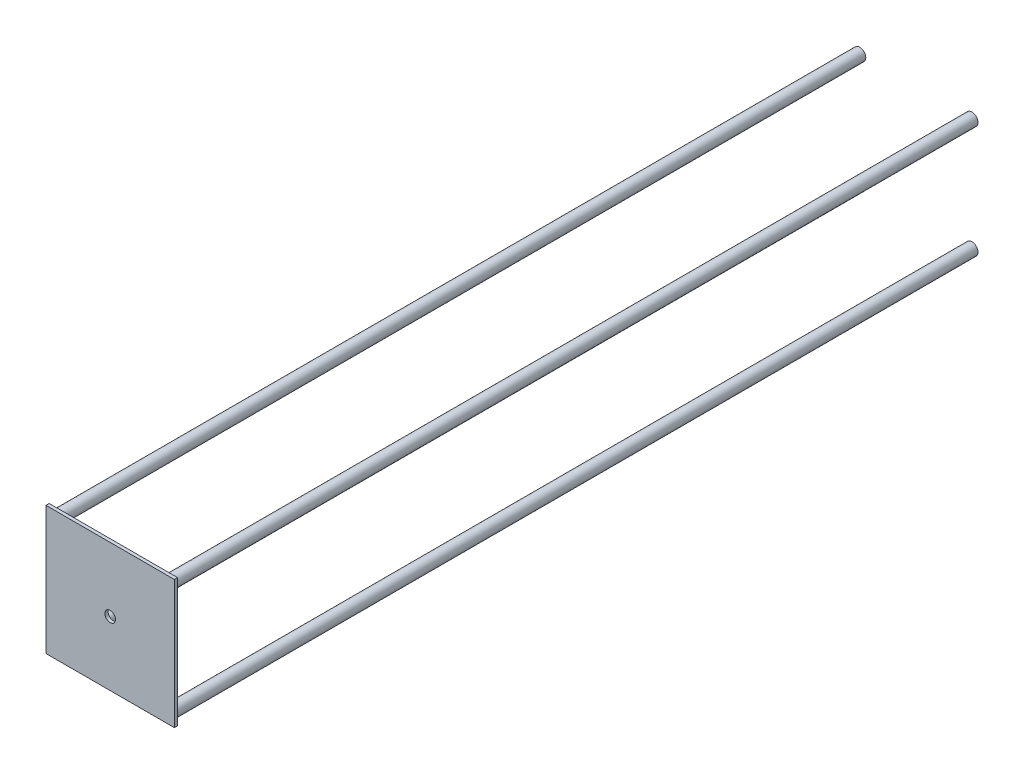
from build123d import *

# Parameters (mm, degrees)
SKETCH1_W           = 101.6
SKETCH1_H           = 101.6
BOSS_EXTRUDE1_DEPTH = 2.54
SKETCH2_R           = 4.826
BOSS_EXTRUDE2_DEPTH = 635
SKETCH3_R           = 4.191
CUT_EXTRUDE1_DEPTH  = 635


with BuildPart() as part:
    # Sketch1 → Boss-Extrude1 (new body)
    with BuildSketch(Plane.XY):
        Rectangle(SKETCH1_W, SKETCH1_H)
    extrude(amount=BOSS_EXTRUDE1_DEPTH)

    # Sketch2 → Boss-Extrude2 (add)
    with BuildSketch(Plane(origin=(0, 0, 0), x_dir=(-1, 0, 0), z_dir=(0, 0, -1))):
        with Locations((-44.45, 44.45)):
            Circle(SKETCH2_R)
        with Locations((44.377290972, 44.45)):
            Circle(SKETCH2_R)
        with Locations((44.377290972, -44.45)):
            Circle(SKETCH2_R)
        with Locations((-44.45, -44.45)):
            Circle(SKETCH2_R)
    extrude(amount=BOSS_EXTRUDE2_DEPTH)

    # Sketch3 → Cut-Extrude1 (cut)
    with BuildSketch(Plane.XY.offset(2.54)):
        Circle(SKETCH3_R)
    extrude(amount=-CUT_EXTRUDE1_DEPTH, mode=Mode.SUBTRACT)


solid = part.part
